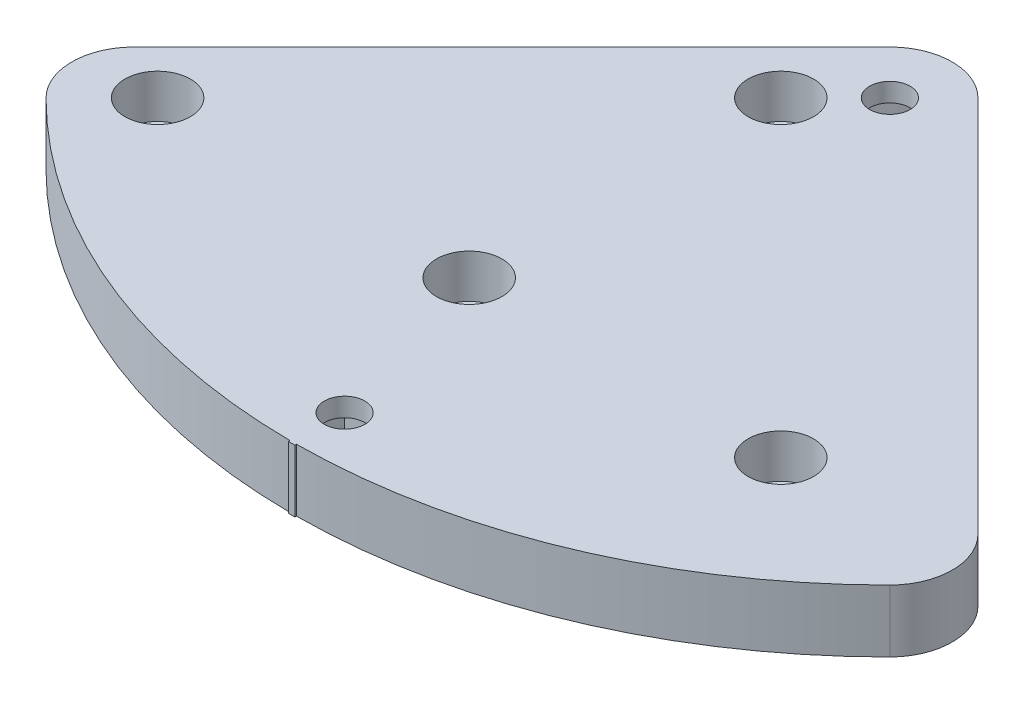
from build123d import *

# Parameters (mm, degrees)
SKETCH_1_R          = 3.2
EXTRUDE_1_DEPTH     = 10
SKETCH_2_R          = 5.25
CUT_EXTRUDE_1_DEPTH = 7
SKETCH_3_R          = 3.25
CUT_EXTRUDE_2_DEPTH = 10
SKETCH_4_R          = 3.25
SKETCH_4_W          = 10.4
SKETCH_4_H          = 10.4
CUT_EXTRUDE_3_DEPTH = 7
EXTRUDE_2_DEPTH     = 10


with BuildPart() as part:
    # 스케치1 → 보스-돌출1 (new body)
    with BuildSketch(Plane(origin=(0, 0, 0), x_dir=(1, 0, 0), z_dir=(0, 1, 0))):
        with BuildLine():
            Line((-7.071067812, 7.071067812), (-67.705474299, -53.563338675))
            ThreePointArc((-67.705474299, -53.563338675), (-70.634406487, -60.634406487), (-67.705474299, -67.705474299))
            ThreePointArc((-67.705474299, -67.705474299), (0, -95.75), (67.705474299, -67.705474299))
            ThreePointArc((67.705474299, -67.705474299), (70.634406487, -60.634406487), (67.705474299, -53.563338675))
            Line((67.705474299, -53.563338675), (7.071067812, 7.071067812))
            ThreePointArc((7.071067812, 7.071067812), (0, 10), (-7.071067812, 7.071067812))
        make_face()
        with Locations((-8.75, -58.75)):
            Circle(SKETCH_1_R, mode=Mode.SUBTRACT)
        with Locations((-8.75, -8.75)):
            Circle(SKETCH_1_R, mode=Mode.SUBTRACT)
        with Locations((-58.75, -58.75)):
            Circle(SKETCH_1_R, mode=Mode.SUBTRACT)
        with Locations((41.25, -58.75)):
            Circle(SKETCH_1_R, mode=Mode.SUBTRACT)
    extrude(amount=EXTRUDE_1_DEPTH)

    # 스케치2 → 컷-돌출1 (cut)
    with BuildSketch(Plane(origin=(0, 10, 0), x_dir=(1, 0, 0), z_dir=(0, 1, 0))):
        with Locations((-8.75, -8.75)):
            Circle(SKETCH_2_R)
        with Locations((-58.75, -58.75)):
            Circle(SKETCH_2_R)
        with Locations((41.25, -58.75)):
            Circle(SKETCH_2_R)
        with Locations((-8.75, -58.75)):
            Circle(SKETCH_2_R)
    extrude(amount=-CUT_EXTRUDE_1_DEPTH, mode=Mode.SUBTRACT)

    # 스케치3 → 컷-돌출2 (cut)
    with BuildSketch(Plane(origin=(0, 10, 0), x_dir=(1, 0, 0), z_dir=(0, 1, 0))):
        Circle(SKETCH_3_R)
        with Locations((0, -87.5)):
            Circle(SKETCH_3_R)
    extrude(amount=-CUT_EXTRUDE_2_DEPTH, mode=Mode.SUBTRACT)

    # 스케치4 → 컷-돌출3 (cut)
    with BuildSketch(Plane.XZ):
        Polygon((0, 7.353910524), (-7.353910524, 0), (0, -7.353910524), (7.353910524, 0), align=None)
        Circle(SKETCH_4_R, mode=Mode.SUBTRACT)
        with Locations((0, 87.5)):
            Rectangle(SKETCH_4_W, SKETCH_4_H)
        with Locations((0, 87.5)):
            Circle(SKETCH_4_R, mode=Mode.SUBTRACT)
    extrude(amount=-CUT_EXTRUDE_3_DEPTH, mode=Mode.SUBTRACT)

    # 스케치5 → 보스-돌출2 (add)
    with BuildSketch(Plane(origin=(0, 10, 0), x_dir=(1, 0, 0), z_dir=(0, 1, 0))):
        with BuildLine():
            Line((0.505263158, -95.998670351), (0.5, -94.998684201))
            ThreePointArc((0.5, -94.998684201), (0, -95), (-0.5, -94.998684201))
            Line((-0.5, -94.998684201), (-0.505263158, -95.998670351))
            ThreePointArc((-0.505263158, -95.998670351), (0, -96), (0.505263158, -95.998670351))
        make_face()
    extrude(amount=-EXTRUDE_2_DEPTH)


solid = part.part
